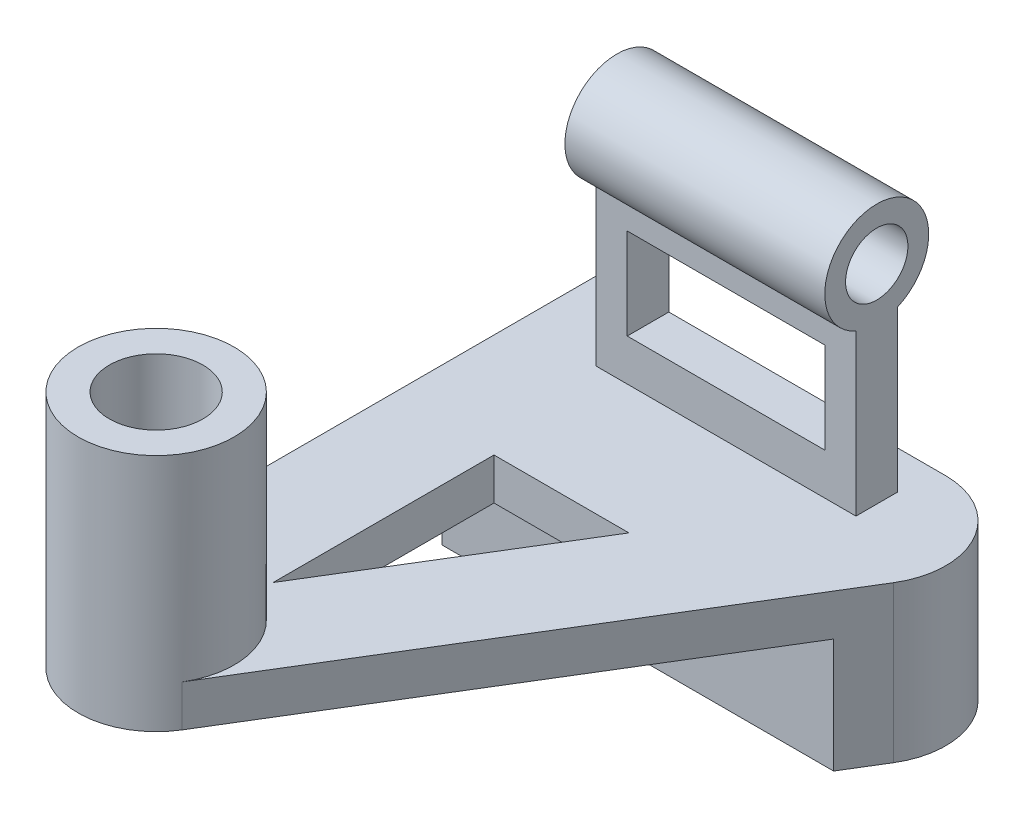
from build123d import *

# Parameters (mm, degrees)
BASE_TRIANGLE_DEPTH   = 8
SKETCH2_W             = 50
SKETCH2_H             = 8
RECTANGLE_BLOCK_DEPTH = 38
CUT_EXTRUDE2_REACH    = 17.365
SKETCH3_W             = 38
SKETCH3_H             = 18
CYINDER_BLOCK_DEPTH   = 50
CUT_EXTRUDE3_REACH    = 68.918
SKETCH5_R             = 6
BOSS_EXTRUDE5_DEPTH   = 50
CUT_EXTRUDE4_DEPTH    = 50
SKETCH11_R            = 6
CUT_EXTRUDE5_DEPTH    = 50
CUT_EXTRUDE6_REACH    = 17.365
SKETCH12_W            = 38
SKETCH12_H            = 17.507702416
BOSS_EXTRUDE6_DEPTH   = 38
CUT_EXTRUDE7_REACH    = 48
SKETCH14_R            = 9
CUT_EXTRUDE9_REACH    = 10
BOSS_EXTRUDE7_DEPTH   = 22


with BuildPart() as part:
    # Sketch1 → Base triangle (new body)
    with BuildSketch(Plane(origin=(0, 0, 0), x_dir=(1, 0, 0), z_dir=(0, 1, 0))):
        with BuildLine():
            Line((0, -54.608695652), (0, 45.391304348))
            Line((0, 45.391304348), (66.917901683, 45.391304348))
            ThreePointArc((66.917901683, 45.391304348), (80, 37.730153279), (79.71890745, 22.572464832))
            Line((79.71890745, 22.572464832), (27.801005766, -62.427535168))
            ThreePointArc((27.801005766, -62.427535168), (10.938909413, -69.048485929), (0, -54.608695652))
        make_face()
    extrude(amount=BASE_TRIANGLE_DEPTH)

    # Sketch2 → Rectangle Block (add)
    with BuildSketch(Plane(origin=(0, 8, 0), x_dir=(1, 0, 0), z_dir=(0, 1, 0))):
        with Locations((40, 34.025974009)):
            Rectangle(SKETCH2_W, SKETCH2_H)
    extrude(amount=RECTANGLE_BLOCK_DEPTH)

    # Sketch3 → Cut-Extrude2 (cut, up to next)
    with BuildSketch(Plane.XY.offset(-30.025974009), mode=Mode.PRIVATE) as cut_extrude2_sk1:
        with Locations((40, 25)):
            Rectangle(SKETCH3_W, SKETCH3_H)
    cut_extrude2_tool1 = extrude(cut_extrude2_sk1.sketch, amount=-CUT_EXTRUDE2_REACH, mode=Mode.PRIVATE) & part.part
    add(cut_extrude2_tool1.solids().sort_by_distance((40, 25, -30.025974))[0], mode=Mode.SUBTRACT)

    # Sketch4 → Cyinder Block (add)
    with BuildSketch(Plane.ZY.offset(-15)):
        with BuildLine():
            ThreePointArc((-24.025974009, 55.16515139), (-39.503199584, 63.531751655), (-38.025974009, 46))
            Line((-38.025974009, 46), (-30.025974009, 46))
            ThreePointArc((-30.025974009, 46), (-25.659373744, 49.687925815), (-24.025974009, 55.16515139))
        make_face()
        with BuildLine():
            Line((-30.025974009, 46), (-38.025974009, 46))
            ThreePointArc((-38.025974009, 46), (-34.025974009, 45.16515139), (-30.025974009, 46))
        make_face()
    extrude(amount=-CYINDER_BLOCK_DEPTH)

    # Sketch5 → Cut-Extrude3 (cut, up to next)
    with BuildSketch(Plane.ZY.offset(-15), mode=Mode.PRIVATE) as cut_extrude3_sk1:
        with Locations((-34.025974009, 55.16515139)):
            Circle(SKETCH5_R)
    cut_extrude3_tool1 = extrude(cut_extrude3_sk1.sketch, amount=-CUT_EXTRUDE3_REACH, mode=Mode.PRIVATE) & part.part
    add(cut_extrude3_tool1.solids().sort_by_distance((15, 55.165151, -34.025974))[0], mode=Mode.SUBTRACT)

    # Sketch9 → Boss-Extrude5 (add)
    with BuildSketch(Plane(origin=(65, 0, 0), x_dir=(0, 0, -1), z_dir=(1, 0, 0))):
        with BuildLine():
            Line((30.025974009, 8), (38.025974009, 8))
            Line((38.025974009, 8), (38.025974009, 38.83484861))
            ThreePointArc((38.025974009, 38.83484861), (34.025974009, 58), (30.025974009, 38.83484861))
            Line((30.025974009, 38.83484861), (30.025974009, 8))
        make_face()
    extrude(amount=-BOSS_EXTRUDE5_DEPTH)

    # Sketch10 → Cut-Extrude4 (cut)
    with BuildSketch(Plane(origin=(65, 0, 0), x_dir=(0, 0, -1), z_dir=(1, 0, 0))):
        with BuildLine():
            ThreePointArc((43.362201908, 51.582575695), (34.025974009, 58), (24.68974611, 51.582575695))
            ThreePointArc((24.68974611, 51.582575695), (34.025974009, 65.16515139), (43.362201908, 51.582575695))
        make_face()
    extrude(amount=-CUT_EXTRUDE4_DEPTH, mode=Mode.SUBTRACT)

    # Sketch11 → Cut-Extrude5 (cut)
    with BuildSketch(Plane(origin=(65, 0, 0), x_dir=(0, 0, -1), z_dir=(1, 0, 0))):
        with Locations((34.025974009, 48)):
            Circle(SKETCH11_R)
    extrude(amount=-CUT_EXTRUDE5_DEPTH, mode=Mode.SUBTRACT)

    # Sketch12 → Cut-Extrude6 (cut, up to next)
    with BuildSketch(Plane.XY.offset(-30.025974009), mode=Mode.PRIVATE) as cut_extrude6_sk1:
        with Locations((40, 24.753851208)):
            Rectangle(SKETCH12_W, SKETCH12_H)
    cut_extrude6_tool1 = extrude(cut_extrude6_sk1.sketch, amount=-CUT_EXTRUDE6_REACH, mode=Mode.PRIVATE) & part.part
    add(cut_extrude6_tool1.solids().sort_by_distance((40, 24.753851, -30.025974))[0], mode=Mode.SUBTRACT)

    # Sketch13 → Boss-Extrude6 (add)
    with BuildSketch(Plane(origin=(0, 8, 0), x_dir=(1, 0, 0), z_dir=(0, 1, 0))):
        with BuildLine():
            ThreePointArc((30, -54.608695652), (15, -39.608695652), (0, -54.608695652))
            ThreePointArc((0, -54.608695652), (10.938909413, -69.048485929), (27.801005766, -62.427535168))
            ThreePointArc((27.801005766, -62.427535168), (29.439790277, -58.669786239), (30, -54.608695652))
        make_face()
    extrude(amount=BOSS_EXTRUDE6_DEPTH)

    # Sketch14 → Cut-Extrude7 (cut, up to next)
    with BuildSketch(Plane(origin=(0, 46, 0), x_dir=(1, 0, 0), z_dir=(0, 1, 0)), mode=Mode.PRIVATE) as cut_extrude7_sk1:
        with Locations((15, -54.608695652)):
            Circle(SKETCH14_R)
    cut_extrude7_tool1 = extrude(cut_extrude7_sk1.sketch, amount=-CUT_EXTRUDE7_REACH, mode=Mode.PRIVATE) & part.part
    add(cut_extrude7_tool1.solids().sort_by_distance((15, 46, 54.608696))[0], mode=Mode.SUBTRACT)

    # Sketch15 → Cut-Extrude9 (cut, up to next)
    with BuildSketch(Plane(origin=(0, 8, 0), x_dir=(1, 0, 0), z_dir=(0, 1, 0)), mode=Mode.PRIVATE) as cut_extrude9_sk1:
        Polygon((20, -37.108695652), (20, 5.391304348), (45.958950842, 5.391304348), align=None)
    cut_extrude9_tool1 = extrude(cut_extrude9_sk1.sketch, amount=-CUT_EXTRUDE9_REACH, mode=Mode.PRIVATE) & part.part
    add(cut_extrude9_tool1.solids().sort_by_distance((28.652984, 8, 8.775362))[0], mode=Mode.SUBTRACT)

    # Sketch20 → Boss-Extrude7 (add)
    with BuildSketch(Plane(origin=(0, 0, 0), x_dir=(-1, 0, 0), z_dir=(0, -1, 0))):
        with BuildLine():
            Line((-75.332662932, 15.391304348), (0, 15.391304348))
            Line((0, 15.391304348), (0, 45.391304348))
            Line((0, 45.391304348), (-66.917901683, 45.391304348))
            ThreePointArc((-66.917901683, 45.391304348), (-80, 37.730153279), (-79.71890745, 22.572464832))
            Line((-79.71890745, 22.572464832), (-75.332662932, 15.391304348))
        make_face()
    extrude(amount=BOSS_EXTRUDE7_DEPTH)


solid = part.part
